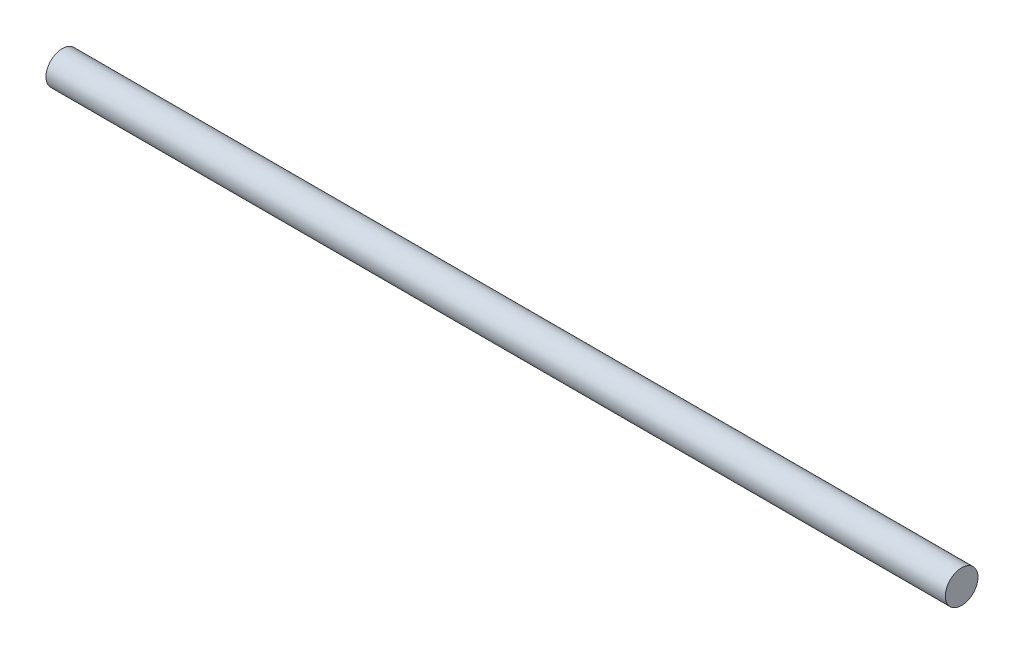
from build123d import *

# Parameters (mm, degrees)
BOSS_EXTRUDE1_DEPTH      = 13.75
BOSS_EXTRUDE1_DEPTH_BACK = 13.75
SKETCH1_R                = 0.5


with BuildPart() as part:
    # Sketch1 → Boss-Extrude1 (new, two sides: drawn at the far end of the back side and taken through both)
    with BuildSketch(Plane(origin=(0, 0, 0), x_dir=(0, 0, -1), z_dir=(1, 0, 0)).offset(-BOSS_EXTRUDE1_DEPTH_BACK)):
        Circle(SKETCH1_R)
    extrude(amount=BOSS_EXTRUDE1_DEPTH + BOSS_EXTRUDE1_DEPTH_BACK)


solid = part.part
